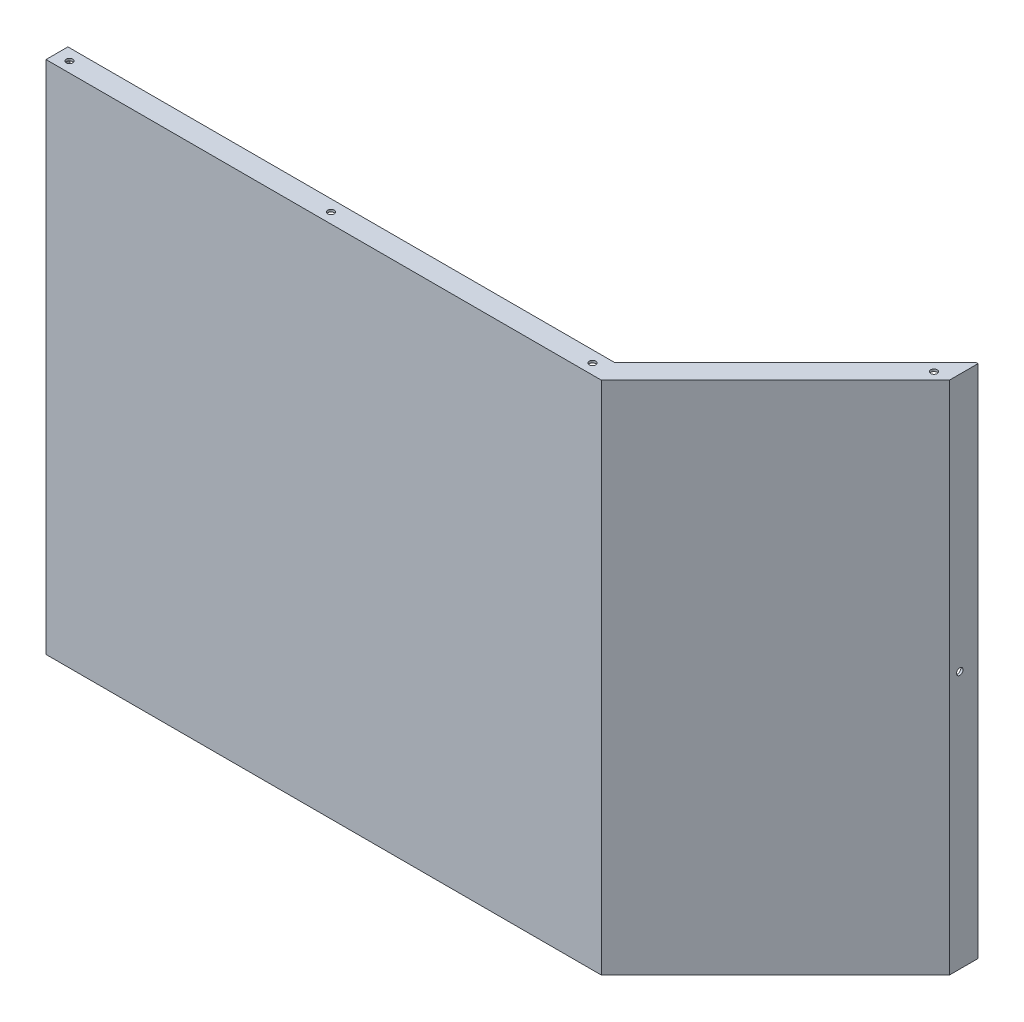
from build123d import *

# Parameters (mm, degrees)
DODANIE_WYCI_GNI_CIE1_DEPTH = 197
DODANIE_WYCI_GNI_CIE2_DEPTH = 1.75
SZKIC3_R                    = 2.5
WYTNIJ_WYCI_GNI_CIE1_DEPTH  = 466
SZKIC4_R                    = 2.5
WYTNIJ_WYCI_GNI_CIE2_DEPTH  = 5
SZKIC5_R                    = 2.5
WYTNIJ_WYCI_GNI_CIE3_DEPTH  = 5


with BuildPart() as part:
    # Szkic1 → Dodanie-wyciągnięcie1 (new body, symmetric)
    with BuildSketch(Plane(origin=(0, 0, 0), x_dir=(1, 0, 0), z_dir=(0, 1, 0))):
        Polygon((-422.25, 0), (0, 0), (132, 132), (132, 153.2), (133.75, 153.2), (133.75, 131.275126266), (0.724873734, -1.75), (-424, -1.75), (-424, 0), (-424, 15), (-422.25, 15), align=None)
    extrude(amount=DODANIE_WYCI_GNI_CIE1_DEPTH, both=True)

    # Szkic2 → Dodanie-wyciągnięcie2 (add)
    with BuildSketch(Plane.XZ.offset(197)):
        Polygon((-422.25, -15), (-422.25, 0), (0, 0), (132, -132), (132, -153.213203436), (-6.213203436, -15), align=None)
    dodanie_wyci_gni_cie2 = extrude(amount=-DODANIE_WYCI_GNI_CIE2_DEPTH)

    # Lustro1: Dodanie-wyciągnięcie2 across plane
    add(dodanie_wyci_gni_cie2.mirror(Plane.ZX))

    # Szkic3 → Wytnij-wyciągnięcie1 (cut)
    with BuildSketch(Plane.XZ.offset(197)):
        with Locations((-414, -6.25)):
            Circle(SZKIC3_R)
        with Locations((-214, -6.25)):
            Circle(SZKIC3_R)
        with Locations((-14, -6.25)):
            Circle(SZKIC3_R)
        with Locations((122.221470087, -131.060304852)):
            Circle(SZKIC3_R)
    extrude(amount=-WYTNIJ_WYCI_GNI_CIE1_DEPTH, mode=Mode.SUBTRACT)

    # Szkic4 → Wytnij-wyciągnięcie2 (cut)
    with BuildSketch(Plane(origin=(133.75, 0, 0), x_dir=(0, 0, -1), z_dir=(1, 0, 0))):
        with Locations((139.275126266, 0)):
            Circle(SZKIC4_R)
    extrude(amount=-WYTNIJ_WYCI_GNI_CIE2_DEPTH, mode=Mode.SUBTRACT)

    # Szkic5 → Wytnij-wyciągnięcie3 (cut)
    with BuildSketch(Plane.ZY.offset(424)):
        with Locations((-6.25, 0)):
            Circle(SZKIC5_R)
    extrude(amount=-WYTNIJ_WYCI_GNI_CIE3_DEPTH, mode=Mode.SUBTRACT)


solid = part.part
